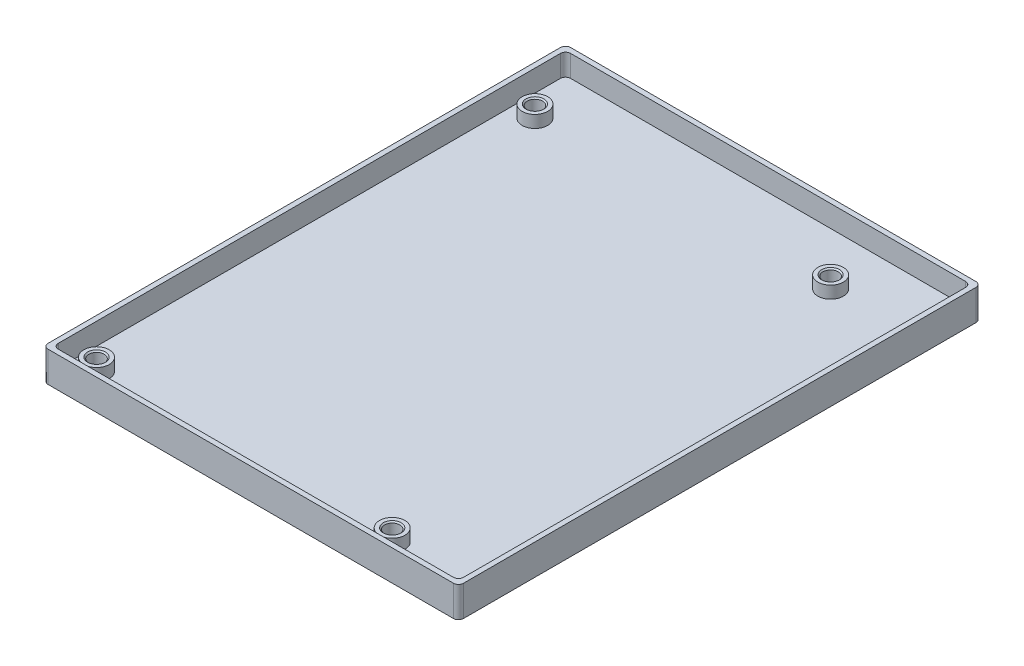
from build123d import *

# Parameters (mm, degrees)
SKETCH1_W           = 81.5
SKETCH1_H           = 102.5
BOSS_EXTRUDE1_DEPTH = 6
SKETCH2_R           = 1.5
CUT_EXTRUDE1_DEPTH  = 7
SKETCH7_W           = 79.5
SKETCH7_H           = 100.5
CUT_EXTRUDE3_DEPTH  = 1.85
SKETCH8_W           = 79.5
SKETCH8_H           = 100.5
SKETCH8_R           = 2.5
CUT_EXTRUDE4_DEPTH  = 2.4
FILLET1_R           = 1
CHAMFER1_SIZE       = 0.25


with BuildPart() as part:
    # Sketch1 → Boss-Extrude1 (new body)
    with BuildSketch(Plane(origin=(0, 0, 0), x_dir=(1, 0, 0), z_dir=(0, 1, 0))):
        Rectangle(SKETCH1_W, SKETCH1_H)
    extrude(amount=BOSS_EXTRUDE1_DEPTH)

    # Sketch2 → Cut-Extrude1 (cut, through all)
    with BuildSketch(Plane(origin=(0, 6, 0), x_dir=(1, 0, 0), z_dir=(0, 1, 0))):
        with Locations((-35.5, -46)):
            Circle(SKETCH2_R)
        with Locations((-35.5, 40)):
            Circle(SKETCH2_R)
        with Locations((22.5, -46)):
            Circle(SKETCH2_R)
        with Locations((22.5, 40)):
            Circle(SKETCH2_R)
    extrude(amount=-CUT_EXTRUDE1_DEPTH, mode=Mode.SUBTRACT)

    # Sketch7 → Cut-Extrude3 (cut)
    with BuildSketch(Plane(origin=(0, 6, 0), x_dir=(1, 0, 0), z_dir=(0, 1, 0))):
        Rectangle(SKETCH7_W, SKETCH7_H)
    extrude(amount=-CUT_EXTRUDE3_DEPTH, mode=Mode.SUBTRACT)

    # Sketch8 → Cut-Extrude4 (cut)
    with BuildSketch(Plane(origin=(0, 4.15, 0), x_dir=(1, 0, 0), z_dir=(0, 1, 0))):
        Rectangle(SKETCH8_W, SKETCH8_H)
        with Locations((-35.5, 40)):
            Circle(SKETCH8_R, mode=Mode.SUBTRACT)
        with Locations((22.5, 40)):
            Circle(SKETCH8_R, mode=Mode.SUBTRACT)
        with Locations((-35.5, -46)):
            Circle(SKETCH8_R, mode=Mode.SUBTRACT)
        with Locations((22.5, -46)):
            Circle(SKETCH8_R, mode=Mode.SUBTRACT)
    extrude(amount=-CUT_EXTRUDE4_DEPTH, mode=Mode.SUBTRACT)

    # Fillet1
    fillet1_edges = [part.edges().sort_by_distance(p)[0] for p in [
        (-39.75, 3.875, 50.25),
        (-39.75, 3.875, -50.25),
        (39.75, 3.875, -50.25),
        (39.75, 3.875, 50.25),
        (-40.75, 3, 51.25),
        (-40.75, 3, -51.25),
        (40.75, 3, -51.25),
        (40.75, 3, 51.25),
    ]]
    fillet(fillet1_edges, radius=FILLET1_R)

    # Chamfer1
    chamfer1_edges = [part.edges().sort_by_distance(p)[0] for p in [
        (-37, 4.15, 46),
        (21, 4.15, -40),
        (21, 4.15, 46),
        (-37, 4.15, -40),
    ]]
    chamfer(chamfer1_edges, length=CHAMFER1_SIZE)


solid = part.part
